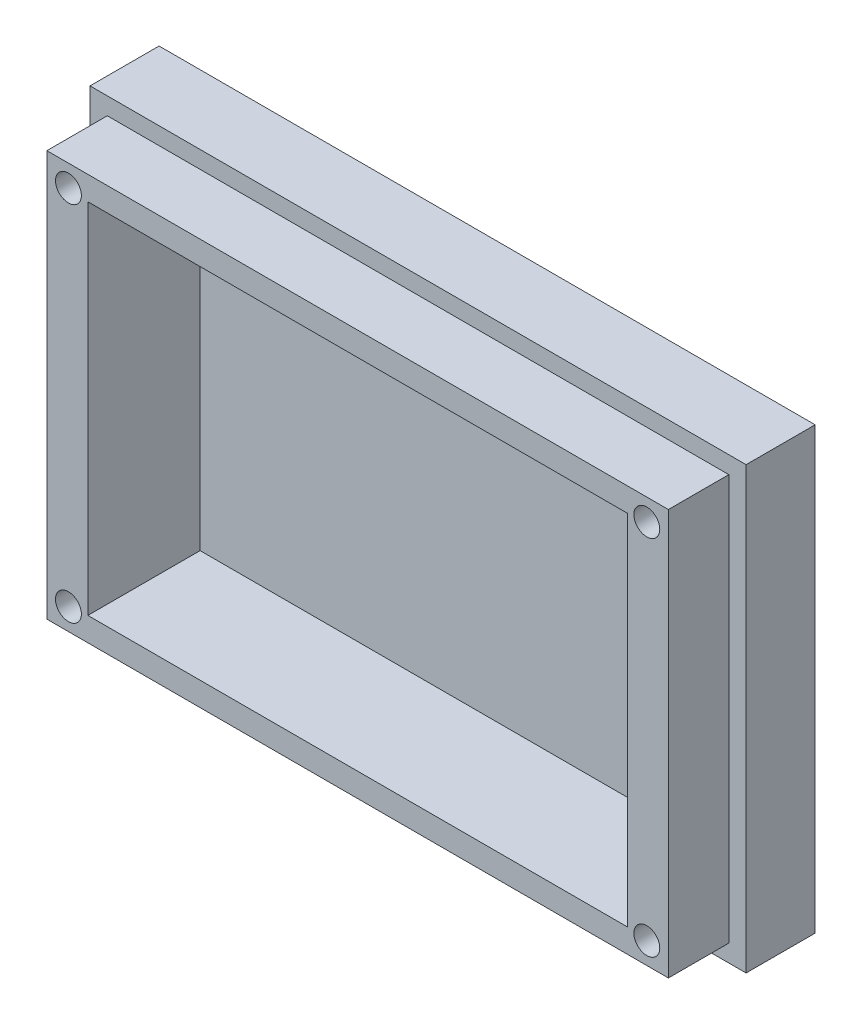
from build123d import *

# Parameters (mm, degrees)
SKETCH_1_W          = 72
SKETCH_1_H          = 47
EXTRUDE_1_DEPTH     = 15
SKETCH_2_W          = 62.5
SKETCH_2_H          = 41.5
CUT_EXTRUDE_1_DEPTH = 13
SKETCH_3_R          = 1.5
CUT_EXTRUDE_3_DEPTH = 16
SKETCH_4_W          = 76
SKETCH_4_H          = 51
SKETCH_4_W_2        = 72
SKETCH_4_H_2        = 47
EXTRUDE_2_DEPTH     = 8


with BuildPart() as part:
    # ｽｹｯﾁ1 → ﾎﾞｽ - 押し出し1 (new body)
    with BuildSketch(Plane.XY):
        with Locations((2.027327289, 3.897905759)):
            Rectangle(SKETCH_1_W, SKETCH_1_H)
    extrude(amount=EXTRUDE_1_DEPTH)

    # ｽｹｯﾁ2 → ｶｯﾄ - 押し出し1 (cut)
    with BuildSketch(Plane.XY.offset(15)):
        with Locations((2.027327289, 3.897905759)):
            Rectangle(SKETCH_2_W, SKETCH_2_H)
    extrude(amount=-CUT_EXTRUDE_1_DEPTH, mode=Mode.SUBTRACT)

    # ｽｹｯﾁ3 → ｶｯﾄ - 押し出し3 (cut, through all)
    with BuildSketch(Plane.XY.offset(15)):
        with Locations((-31.472672711, 24.897905759)):
            Circle(SKETCH_3_R)
        with Locations((35.527327289, 24.897905759)):
            Circle(SKETCH_3_R)
        with Locations((-31.472672711, -17.102094241)):
            Circle(SKETCH_3_R)
        with Locations((35.527327289, -17.102094241)):
            Circle(SKETCH_3_R)
    extrude(amount=-CUT_EXTRUDE_3_DEPTH, mode=Mode.SUBTRACT)

    # ｽｹｯﾁ4 → ﾎﾞｽ - 押し出し2 (add)
    with BuildSketch(Plane(origin=(0, 0, 0), x_dir=(-1, 0, 0), z_dir=(0, 0, -1))):
        with Locations((-2.027327289, 3.897905759)):
            Rectangle(SKETCH_4_W, SKETCH_4_H)
        with Locations((-2.027327289, 3.897905759)):
            Rectangle(SKETCH_4_W_2, SKETCH_4_H_2, mode=Mode.SUBTRACT)
    extrude(amount=-EXTRUDE_2_DEPTH)


solid = part.part
